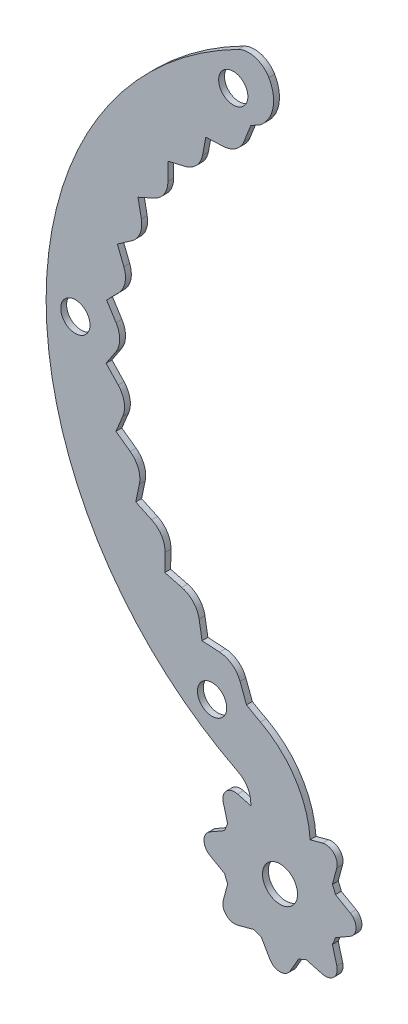
from build123d import *

# Parameters (mm, degrees)
IZIM1_R                     = 5
IZIM1_R_2                   = 2.5
Y_KSEKLIK_EKSTR_ZYON2_DEPTH = 1
IZIM2_R                     = 3
Y_KSEKLIK_EKSTR_ZYON4_DEPTH = 1


with BuildPart() as part:
    # Çizim1 → Yükseklik-Ekstrüzyon2 (new body)
    with BuildSketch(Plane.XY):
        with BuildLine():
            Line((-25, 43.301270189), (-26.146521576, 40.39207739))
            ThreePointArc((-26.146521576, 40.39207739), (-27.544598222, 38.602623821), (-29.691484877, 37.862596744))
            Line((-29.691484877, 37.862596744), (-32.693673826, 37.730024144))
            Line((-32.693673826, 37.730024144), (-33.252115355, 34.777253066))
            ThreePointArc((-33.252115355, 34.777253066), (-34.290118058, 32.757522199), (-36.260310201, 31.628316593))
            Line((-36.260310201, 31.628316593), (-39.184480502, 30.935538106))
            Line((-39.184480502, 30.935538106), (-39.17973637, 27.930427214))
            ThreePointArc((-39.17973637, 27.930427214), (-39.820893366, 25.751969023), (-41.54459596, 24.273587558))
            Line((-41.54459596, 24.273587558), (-44.287157421, 23.045145208))
            Line((-44.287157421, 23.045145208), (-43.719395692, 20.094152054))
            ThreePointArc((-43.719395692, 20.094152054), (-43.940993675, 17.834139505), (-45.357143694, 16.058954583))
            Line((-45.357143694, 16.058954583), (-47.82093971, 14.338366552))
            Line((-47.82093971, 14.338366552), (-46.710273625, 11.546031539))
            ThreePointArc((-46.710273625, 11.546031539), (-46.504462376, 9.284526705), (-47.562892001, 7.275425136))
            Line((-47.562892001, 7.275425136), (-49.660641368, 5.123644113))
            Line((-49.660641368, 5.123644113), (-48.046416828, 2.588887101))
            ThreePointArc((-48.046416828, 2.588887101), (-47.420487313, 0.406004917), (-48.083701146, -1.765839874))
            Line((-48.083701146, -1.765839874), (-49.741090048, -4.272585973))
            Line((-49.741090048, -4.272585973), (-47.680491761, -6.459969953))
            ThreePointArc((-47.680491761, -6.459969953), (-46.656617846, -8.486899797), (-46.901121207, -10.744549126))
            Line((-46.901121207, -10.744549126), (-48.059435816, -13.517457571))
            Line((-48.059435816, -13.517457571), (-45.625461503, -15.279979352))
            ThreePointArc((-45.625461503, -15.279979352), (-44.239914432, -17.079151855), (-44.057045667, -19.342627369))
            Line((-44.057045667, -19.342627369), (-44.675252109, -22.283466496))
            Line((-44.675252109, -22.283466496), (-41.954126526, -23.558687864))
            ThreePointArc((-41.954126526, -23.558687864), (-40.255989993, -25.066366444), (-39.652227319, -27.255483394))
            Line((-39.652227319, -27.255483394), (-39.708425324, -30.260072511))
            Line((-39.708425324, -30.260072511), (-36.7965457, -31.002818113))
            ThreePointArc((-36.7965457, -31.002818113), (-34.84597704, -32.165592505), (-33.842709051, -34.202800331))
            Line((-33.842709051, -34.202800331), (-33.334907776, -37.164700371))
            Line((-33.334907776, -37.164700371), (-30.335428898, -37.348658075))
            ThreePointArc((-30.335428898, -37.348658075), (-28.201527977, -38.125336415), (-26.834295942, -39.938466016))
            Line((-26.834295942, -39.938466016), (-25.73775467, -42.866863479))
            ThreePointArc((-25.73775467, -42.866863479), (-24.554196145, -43.55561332), (-23.352220135, -44.21169319))
            ThreePointArc((-23.352220135, -44.21169319), (-17.219408632, -49.939828574), (-14.829333353, -57.984109281))
            ThreePointArc((-14.829333353, -57.984109281), (-20.099106379, -76.543069457), (-25, -57.883306535))
            Line((-25, -57.883306535), (-25, -57.052607302))
            ThreePointArc((-25, -57.052607302), (-25.590454576, -54.960957236), (-27.1875, -53.486819346))
            ThreePointArc((-27.1875, -53.486819346), (-59.999999835, 0.004450967), (-27.179564099, 53.490852446))
            ThreePointArc((-27.179564099, 53.490852446), (-24.232021318, 53.76021953), (-21.906244367, 51.929556087))
            ThreePointArc((-21.906244367, 51.929556087), (-21.212806241, 47.755648425), (-23.446136356, 44.161959762))
            ThreePointArc((-23.446136356, 44.161959762), (-24.226890609, 43.73851588), (-25, 43.301270189))
        make_face()
        with Locations((-20, -66.543560573)):
            Circle(IZIM1_R, mode=Mode.SUBTRACT)
        with Locations((-31.620079453, -45.001895242)):
            Circle(IZIM1_R_2, mode=Mode.SUBTRACT)
        with Locations((-55, 0)):
            Circle(IZIM1_R_2, mode=Mode.SUBTRACT)
        with Locations((-28.000624989, 47.338831842)):
            Circle(IZIM1_R_2, mode=Mode.SUBTRACT)
    extrude(amount=Y_KSEKLIK_EKSTR_ZYON2_DEPTH)

    # Çizim2 → Yükseklik-Ekstrüzyon4 (add)
    with BuildSketch(Plane.XY.offset(1)):
        with BuildLine():
            Line((-8, -68.275611381), (-10.601540351, -69.777611403))
            ThreePointArc((-10.601540351, -69.777611403), (-11.025419883, -70.260953374), (-11.067466177, -70.902455852))
            Line((-11.067466177, -70.902455852), (-10.289973754, -73.804097076))
            ThreePointArc((-10.289973754, -73.804097076), (-10.807611845, -75.735948729), (-12.739463497, -76.253586819))
            Line((-12.739463497, -76.253586819), (-15.641104722, -75.476094396))
            ThreePointArc((-15.641104722, -75.476094396), (-16.282607199, -75.51814069), (-16.765949171, -75.942020222))
            Line((-16.765949171, -75.942020222), (-18.267949192, -78.543560573))
            ThreePointArc((-18.267949192, -78.543560573), (-20, -79.543560573), (-21.732050808, -78.543560573))
            Line((-21.732050808, -78.543560573), (-23.234050829, -75.942020222))
            ThreePointArc((-23.234050829, -75.942020222), (-23.717392801, -75.51814069), (-24.358895278, -75.476094396))
            Line((-24.358895278, -75.476094396), (-27.260536503, -76.253586819))
            ThreePointArc((-27.260536503, -76.253586819), (-29.192388155, -75.735948729), (-29.710026246, -73.804097076))
            Line((-29.710026246, -73.804097076), (-28.932533823, -70.902455852))
            ThreePointArc((-28.932533823, -70.902455852), (-28.974580117, -70.260953374), (-29.398459649, -69.777611403))
            Line((-29.398459649, -69.777611403), (-32, -68.275611381))
            ThreePointArc((-32, -68.275611381), (-33, -66.543560573), (-32, -64.811509766))
            Line((-32, -64.811509766), (-29.398459649, -63.309509744))
            ThreePointArc((-29.398459649, -63.309509744), (-28.974580117, -62.826167772), (-28.932533823, -62.184665295))
            Line((-28.932533823, -62.184665295), (-29.710026246, -59.28302407))
            ThreePointArc((-29.710026246, -59.28302407), (-29.192388155, -57.351172418), (-27.260536503, -56.833534328))
            Line((-27.260536503, -56.833534328), (-24.358895278, -57.61102675))
            ThreePointArc((-24.358895278, -57.61102675), (-23.717392801, -57.568980457), (-23.234050829, -57.145100924))
            Line((-23.234050829, -57.145100924), (-21.732050808, -54.543560573))
            ThreePointArc((-21.732050808, -54.543560573), (-20, -53.543560573), (-18.267949192, -54.543560573))
            Line((-18.267949192, -54.543560573), (-16.765949171, -57.145100924))
            ThreePointArc((-16.765949171, -57.145100924), (-16.282607199, -57.568980457), (-15.641104722, -57.61102675))
            Line((-15.641104722, -57.61102675), (-12.739463497, -56.833534328))
            ThreePointArc((-12.739463497, -56.833534328), (-10.807611845, -57.351172418), (-10.289973754, -59.28302407))
            Line((-10.289973754, -59.28302407), (-11.067466177, -62.184665295))
            ThreePointArc((-11.067466177, -62.184665295), (-11.025419883, -62.826167772), (-10.601540351, -63.309509744))
            Line((-10.601540351, -63.309509744), (-8, -64.811509766))
            ThreePointArc((-8, -64.811509766), (-7, -66.543560573), (-8, -68.275611381))
        make_face()
        with Locations((-20, -66.543560573)):
            Circle(IZIM2_R, mode=Mode.SUBTRACT)
    extrude(amount=-Y_KSEKLIK_EKSTR_ZYON4_DEPTH)


solid = part.part
